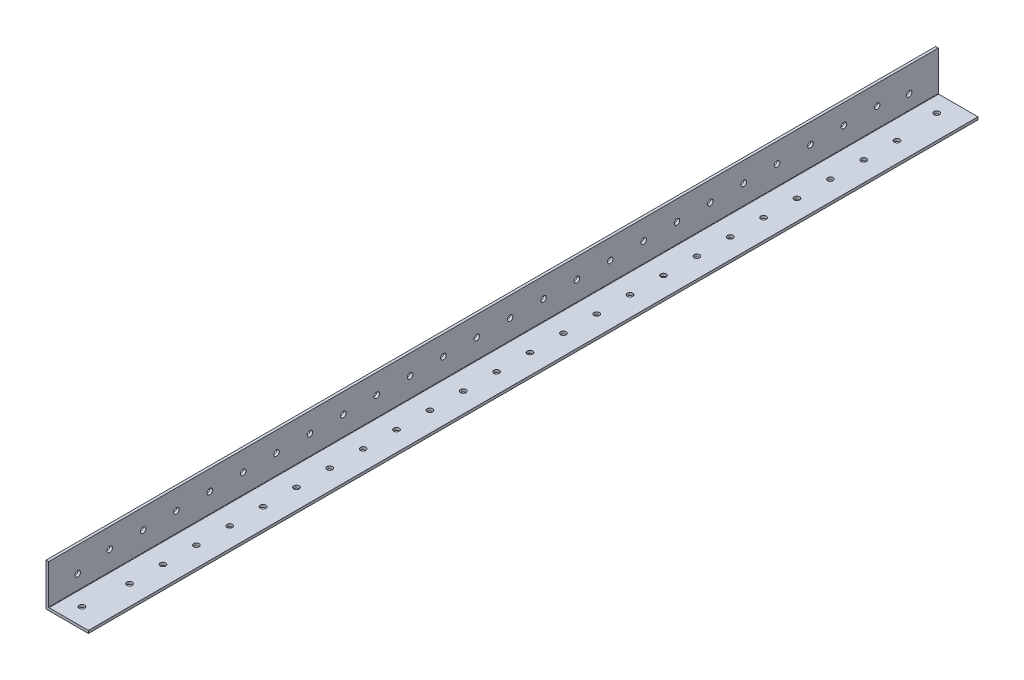
from build123d import *

# Parameters (mm, degrees)
BOSS_EXTRUDE1_DEPTH = 1219.2
FILLET1_R           = 0.254
SKETCH4_W           = 1905.2
SKETCH4_H           = 74.945320812
CUT_EXTRUDE1_DEPTH  = 60
SKETCH9_R           = 1.65
CUT_EXTRUDE5_DEPTH  = 60
SKETCH10_R          = 1.65
CUT_EXTRUDE6_DEPTH  = 60


with BuildPart() as part:
    # Sketch3 → Boss-Extrude1 (new, symmetric)
    with BuildSketch(Plane.XY):
        Polygon((1.5875, 25.4), (0, 25.4), (0, 0), (25.4, 0), (25.4, 1.5875), (1.5875, 1.5875), align=None)
    extrude(amount=BOSS_EXTRUDE1_DEPTH, both=True)

    # Fillet1
    fillet1_edges = [part.edges().sort_by_distance(p)[0] for p in [
        (1.5875, 1.5875, 0),
    ]]
    fillet(fillet1_edges, radius=FILLET1_R)

    # Sketch4 → Cut-Extrude1 (cut)
    with BuildSketch(Plane.ZY):
        with Locations((-266.6, 37.472660406)):
            Rectangle(SKETCH4_W, SKETCH4_H)
    extrude(amount=-CUT_EXTRUDE1_DEPTH, mode=Mode.SUBTRACT)

    # Sketch9 → Cut-Extrude5 (cut)
    with BuildSketch(Plane(origin=(1.5875, 0, 0), x_dir=(0, 0, -1), z_dir=(1, 0, 0))):
        with Locations((-1201.7375, 10.3759)):
            Circle(SKETCH9_R)
        with Locations((-703.4625, 10.3759)):
            Circle(SKETCH9_R)
        with Locations((-722.6, 13.49375)):
            Circle(SKETCH9_R)
        with Locations((-742.6, 13.49375)):
            Circle(SKETCH9_R)
        with Locations((-762.6, 13.49375)):
            Circle(SKETCH9_R)
        with Locations((-782.6, 13.49375)):
            Circle(SKETCH9_R)
        with Locations((-802.6, 13.49375)):
            Circle(SKETCH9_R)
        with Locations((-822.6, 13.49375)):
            Circle(SKETCH9_R)
        with Locations((-842.6, 13.49375)):
            Circle(SKETCH9_R)
        with Locations((-862.6, 13.49375)):
            Circle(SKETCH9_R)
        with Locations((-882.6, 13.49375)):
            Circle(SKETCH9_R)
        with Locations((-902.6, 13.49375)):
            Circle(SKETCH9_R)
        with Locations((-922.6, 13.49375)):
            Circle(SKETCH9_R)
        with Locations((-942.6, 13.49375)):
            Circle(SKETCH9_R)
        with Locations((-962.6, 13.49375)):
            Circle(SKETCH9_R)
        with Locations((-982.6, 13.49375)):
            Circle(SKETCH9_R)
        with Locations((-1002.6, 13.49375)):
            Circle(SKETCH9_R)
        with Locations((-1022.6, 13.49375)):
            Circle(SKETCH9_R)
        with Locations((-1042.6, 13.49375)):
            Circle(SKETCH9_R)
        with Locations((-1062.6, 13.49375)):
            Circle(SKETCH9_R)
        with Locations((-1082.6, 13.49375)):
            Circle(SKETCH9_R)
        with Locations((-1102.6, 13.49375)):
            Circle(SKETCH9_R)
        with Locations((-1122.6, 13.49375)):
            Circle(SKETCH9_R)
        with Locations((-1142.6, 13.49375)):
            Circle(SKETCH9_R)
        with Locations((-1162.6, 13.49375)):
            Circle(SKETCH9_R)
        with Locations((-1182.6, 13.49375)):
            Circle(SKETCH9_R)
    extrude(amount=-CUT_EXTRUDE5_DEPTH, mode=Mode.SUBTRACT)

    # Sketch10 → Cut-Extrude6 (cut)
    with BuildSketch(Plane(origin=(0, 1.5875, 0), x_dir=(1, 0, 0), z_dir=(0, 1, 0))):
        with Locations(Location((11.1125, -696.408204333, 0), (0, 0, 180))):
            Circle(SKETCH10_R)
        with Locations(Location((11.1125, -1208.791795667, 0), (0, 0, 180))):
            Circle(SKETCH10_R)
        with Locations(Location((13.49375, -1182.6, 0), (0, 0, 180))):
            Circle(SKETCH10_R)
        with Locations(Location((13.49375, -1162.6, 0), (0, 0, 180))):
            Circle(SKETCH10_R)
        with Locations(Location((13.49375, -1142.6, 0), (0, 0, 180))):
            Circle(SKETCH10_R)
        with Locations(Location((13.49375, -1122.6, 0), (0, 0, 180))):
            Circle(SKETCH10_R)
        with Locations(Location((13.49375, -1102.6, 0), (0, 0, 180))):
            Circle(SKETCH10_R)
        with Locations(Location((13.49375, -1082.6, 0), (0, 0, 180))):
            Circle(SKETCH10_R)
        with Locations(Location((13.49375, -1062.6, 0), (0, 0, 180))):
            Circle(SKETCH10_R)
        with Locations(Location((13.49375, -1042.6, 0), (0, 0, 180))):
            Circle(SKETCH10_R)
        with Locations(Location((13.49375, -1022.6, 0), (0, 0, 180))):
            Circle(SKETCH10_R)
        with Locations(Location((13.49375, -1002.6, 0), (0, 0, 180))):
            Circle(SKETCH10_R)
        with Locations(Location((13.49375, -982.6, 0), (0, 0, 180))):
            Circle(SKETCH10_R)
        with Locations(Location((13.49375, -962.6, 0), (0, 0, 180))):
            Circle(SKETCH10_R)
        with Locations(Location((13.49375, -942.6, 0), (0, 0, 180))):
            Circle(SKETCH10_R)
        with Locations(Location((13.49375, -922.6, 0), (0, 0, 180))):
            Circle(SKETCH10_R)
        with Locations(Location((13.49375, -902.6, 0), (0, 0, 180))):
            Circle(SKETCH10_R)
        with Locations(Location((13.49375, -882.6, 0), (0, 0, 180))):
            Circle(SKETCH10_R)
        with Locations(Location((13.49375, -862.6, 0), (0, 0, 180))):
            Circle(SKETCH10_R)
        with Locations(Location((13.49375, -842.6, 0), (0, 0, 180))):
            Circle(SKETCH10_R)
        with Locations(Location((13.49375, -822.6, 0), (0, 0, 180))):
            Circle(SKETCH10_R)
        with Locations(Location((13.49375, -802.6, 0), (0, 0, 180))):
            Circle(SKETCH10_R)
        with Locations(Location((13.49375, -782.6, 0), (0, 0, 180))):
            Circle(SKETCH10_R)
        with Locations(Location((13.49375, -762.6, 0), (0, 0, 180))):
            Circle(SKETCH10_R)
        with Locations(Location((13.49375, -742.6, 0), (0, 0, 180))):
            Circle(SKETCH10_R)
        with Locations(Location((13.49375, -722.6, 0), (0, 0, 180))):
            Circle(SKETCH10_R)
    extrude(amount=-CUT_EXTRUDE6_DEPTH, mode=Mode.SUBTRACT)


solid = part.part
